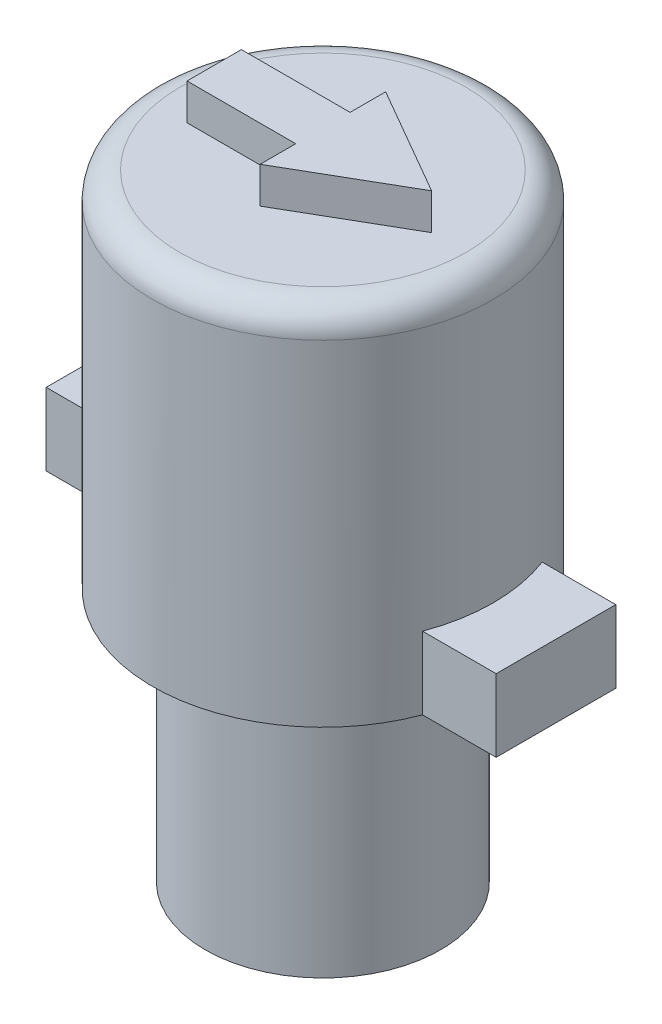
from build123d import *

# Parameters (mm, degrees)
SKETCH1_R           = 3.25
BOSS_EXTRUDE1_DEPTH = 7.018
SKETCH6_R           = 4.7
BOSS_EXTRUDE2_DEPTH = 10
FILLET1_R           = 0.75
BOSS_EXTRUDE3_DEPTH = 1
BOSS_EXTRUDE4_DEPTH = 2


with BuildPart() as part:
    # Sketch1 → Boss-Extrude1 (new body)
    with BuildSketch(Plane(origin=(0, 0, 0), x_dir=(1, 0, 0), z_dir=(0, 1, 0))):
        Circle(SKETCH1_R)
    extrude(amount=BOSS_EXTRUDE1_DEPTH)

    # Sketch6 → Boss-Extrude2 (add)
    with BuildSketch(Plane(origin=(0, 7.018, 0), x_dir=(1, 0, 0), z_dir=(0, 1, 0))):
        Circle(SKETCH6_R)
    extrude(amount=BOSS_EXTRUDE2_DEPTH)

    # Fillet1
    fillet1_edges = [part.edges().sort_by_distance(p)[0] for p in [
        (-4.7, 17.018, 0),
    ]]
    fillet(fillet1_edges, radius=FILLET1_R)

    # Sketch8 → Boss-Extrude3 (add)
    with BuildSketch(Plane(origin=(0, 17.018, 0), x_dir=(1, 0, 0), z_dir=(0, 1, 0))):
        Polygon((0, 0.75), (-3, 0.75), (-3, -0.75), (0, -0.75), (0, -1.732050808), (3, 0), (0, 1.732050808), align=None)
    extrude(amount=BOSS_EXTRUDE3_DEPTH)

    # Sketch9 → Boss-Extrude4 (add)
    with BuildSketch(Plane.XZ.offset(-7.018)):
        with BuildLine():
            Line((-4.588871757, 1.016), (-6.620871757, 1.016))
            Line((-6.620871757, 1.016), (-6.620871757, -1.016))
            Line((-6.620871757, -1.016), (-4.588871757, -1.016))
            ThreePointArc((-4.588871757, -1.016), (-4.7, 0), (-4.588871757, 1.016))
        make_face()
        with BuildLine():
            Line((4.400477133, 1.651), (6.432477133, 1.651))
            Line((6.432477133, 1.651), (6.432477133, -1.651))
            Line((6.432477133, -1.651), (4.400477133, -1.651))
            ThreePointArc((4.400477133, -1.651), (4.7, 0), (4.400477133, 1.651))
        make_face()
    extrude(amount=-BOSS_EXTRUDE4_DEPTH)


solid = part.part
